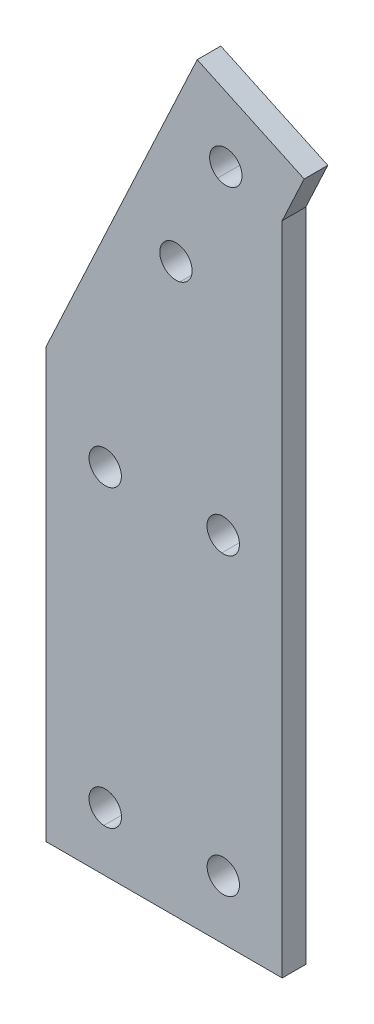
from build123d import *

# Parameters (mm, degrees)
BOSS_EXTRUDE1_DEPTH = 4


with BuildPart() as part:
    # Sketch2 → Boss-Extrude1 (new body)
    with BuildSketch(Plane.XY):
        Polygon((-243.202124872, -545.912292309), (-261.32800293, -537.460021973), (-286.920013428, -592.342041016), (-286.920013428, -665.044006348), (-246.92041444, -665.044006348), (-246.92041444, -553.886157392), align=None)
        with BuildLine():
            ThreePointArc((-256.682006836, -652.315040871), (-259.638579462, -654.80647695), (-257.159011841, -657.773010254))
            ThreePointArc((-257.159011841, -657.773010254), (-254.180566252, -655.283485786), (-256.682006836, -652.315040871))
        make_face(mode=Mode.SUBTRACT)
        with BuildLine():
            ThreePointArc((-276.920013428, -652.294006348), (-279.672667512, -654.918648036), (-277.159011841, -657.773010254))
            ThreePointArc((-277.159011841, -657.773010254), (-274.171775379, -655.158601231), (-276.920013428, -652.294006348))
        make_face(mode=Mode.SUBTRACT)
        with BuildLine():
            ThreePointArc((-276.136016846, -602.418029785), (-279.582956118, -604.374783929), (-277.476013184, -607.732025146))
            ThreePointArc((-277.476013184, -607.732025146), (-274.263780083, -605.716086644), (-276.136016846, -602.418029785))
        make_face(mode=Mode.SUBTRACT)
        with BuildLine():
            ThreePointArc((-256.682006836, -602.315002441), (-259.662954971, -604.8043291), (-257.159011841, -607.773010254))
            ThreePointArc((-257.159011841, -607.773010254), (-254.180547037, -605.283466564), (-256.682006836, -602.315002441))
        make_face(mode=Mode.SUBTRACT)
        with BuildLine():
            ThreePointArc((-265.17401123, -566.142028809), (-267.635869624, -569.341884059), (-264.25201416, -571.544006348))
            ThreePointArc((-264.25201416, -571.544006348), (-262.235793714, -568.420211554), (-265.17401123, -566.142028809))
        make_face(mode=Mode.SUBTRACT)
        with BuildLine():
            ThreePointArc((-254.228012085, -549.178039551), (-258.493761484, -548.880446167), (-257.878021241, -553.111999511))
            ThreePointArc((-257.878021241, -553.111999511), (-254.467220991, -552.616353449), (-254.228012085, -549.178039551))
        make_face(mode=Mode.SUBTRACT)
    extrude(amount=BOSS_EXTRUDE1_DEPTH)


solid = part.part
